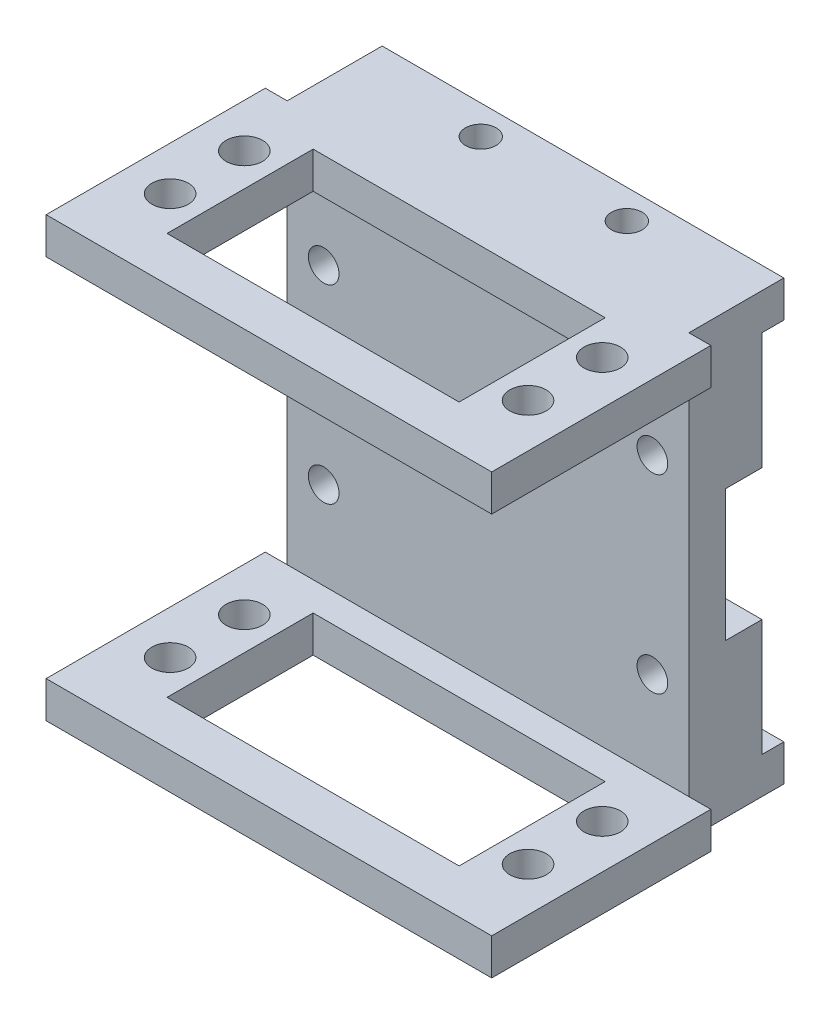
from build123d import *

# Parameters (mm, degrees)
BOSS_EXTRUDE1_DEPTH   = 5
BOSS_EXTRUDE1_2_DEPTH = 5
BOSS_EXTRUDE1_3_DEPTH = 5
BOSS_EXTRUDE1_4_DEPTH = 5
SKETCH2_W             = 55
SKETCH2_H             = 50
BOSS_EXTRUDE2_DEPTH   = 5
SKETCH3_W             = 55
SKETCH3_H             = 13
SKETCH3_R             = 2.1
BOSS_EXTRUDE3_DEPTH   = 5
SKETCH4_W             = 61
SKETCH4_H             = 30
BOSS_EXTRUDE4_DEPTH   = 5
SKETCH5_R             = 2.5
SKETCH5_W             = 39.983210939
SKETCH5_H             = 20
CUT_EXTRUDE3_DEPTH    = 5
SKETCH7_R             = 2.1
CUT_EXTRUDE4_DEPTH    = 14


with BuildPart() as part:
    # Sketch1 → Boss-Extrude1 (new body)
    with BuildSketch(Plane.XY):
        with BuildLine():
            Line((23.840984083, 9.134098408), (28.840984083, 9.134098408))
            Line((28.840984083, 9.134098408), (28.840984083, 25.134098408))
            Line((28.840984083, 25.134098408), (19.840984083, 25.134098408))
            Line((19.840984083, 25.134098408), (19.840984083, 13.134098408))
            ThreePointArc((19.840984083, 13.134098408), (21.012556959, 10.305671284), (23.840984083, 9.134098408))
        make_face()
    extrude(amount=BOSS_EXTRUDE1_DEPTH)



with BuildPart() as body_2:
    # Sketch1 → Boss-Extrude1 2 (new body)
    with BuildSketch(Plane.XY):
        with BuildLine():
            Line((-26.159015917, 9.134098408), (-21.159015917, 9.134098408))
            ThreePointArc((-21.159015917, 9.134098408), (-18.330588792, 10.305671284), (-17.159015917, 13.134098408))
            Line((-17.159015917, 13.134098408), (-17.159015917, 25.134098408))
            Line((-17.159015917, 25.134098408), (-26.159015917, 25.134098408))
            Line((-26.159015917, 25.134098408), (-26.159015917, 9.134098408))
        make_face()
    extrude(amount=BOSS_EXTRUDE1_2_DEPTH)


with BuildPart() as body_3:
    # Sketch1 → Boss-Extrude1 3 (new body)
    with BuildSketch(Plane.XY):
        with BuildLine():
            Line((28.840984083, -8.865901592), (23.840984083, -8.865901592))
            ThreePointArc((23.840984083, -8.865901592), (21.012556959, -10.037474467), (19.840984083, -12.865901592))
            Line((19.840984083, -12.865901592), (19.840984083, -24.865901592))
            Line((19.840984083, -24.865901592), (28.840984083, -24.865901592))
            Line((28.840984083, -24.865901592), (28.840984083, -8.865901592))
        make_face()
    extrude(amount=BOSS_EXTRUDE1_3_DEPTH)


with BuildPart() as body_4:
    # Sketch1 → Boss-Extrude1 4 (new body)
    with BuildSketch(Plane.XY):
        with BuildLine():
            Line((-17.159015917, -24.865901592), (-17.159015917, -12.865901592))
            ThreePointArc((-17.159015917, -12.865901592), (-18.330588792, -10.037474467), (-21.159015917, -8.865901592))
            Line((-21.159015917, -8.865901592), (-26.159015917, -8.865901592))
            Line((-26.159015917, -8.865901592), (-26.159015917, -24.865901592))
            Line((-26.159015917, -24.865901592), (-17.159015917, -24.865901592))
        make_face()
    extrude(amount=BOSS_EXTRUDE1_4_DEPTH)


with BuildPart() as part_1:
    add(part.part)

    add(body_2.part)  # Boss-Extrude2 merges body 2

    add(body_3.part)  # Boss-Extrude2 merges body 3

    add(body_4.part)  # Boss-Extrude2 merges body 4
    # Sketch2 → Boss-Extrude2 (add)
    with BuildSketch(Plane.XY.offset(5)):
        with Locations((1.340984083, 0.134098408)):
            Rectangle(SKETCH2_W, SKETCH2_H)
    extrude(amount=BOSS_EXTRUDE2_DEPTH)

    # Sketch3 → Boss-Extrude3 (add)
    with BuildSketch(Plane(origin=(0, 25.134098408, 0), x_dir=(1, 0, 0), z_dir=(0, 1, 0))):
        with Locations((1.340984083, -3.5)):
            Rectangle(SKETCH3_W, SKETCH3_H)
        with Locations((-8.659015917, -1)):
            Circle(SKETCH3_R, mode=Mode.SUBTRACT)
        with Locations((11.340984083, -1)):
            Circle(SKETCH3_R, mode=Mode.SUBTRACT)
    boss_extrude3 = extrude(amount=BOSS_EXTRUDE3_DEPTH)

    # Mirror1: Boss-Extrude3 across plane
    add(boss_extrude3.mirror(Plane(origin=(0, 0.134098408, 0), x_dir=(0, 0, 1), z_dir=(0, -1, 0))))

    # Sketch4 → Boss-Extrude4 (add)
    with BuildSketch(Plane(origin=(0, 30.134098408, 0), x_dir=(1, 0, 0), z_dir=(0, 1, 0))):
        with Locations((1.340984083, -25)):
            Rectangle(SKETCH4_W, SKETCH4_H)
    boss_extrude4 = extrude(amount=-BOSS_EXTRUDE4_DEPTH)

    # Mirror2: Boss-Extrude4 across plane
    add(boss_extrude4.mirror(Plane(origin=(0, 0.134098408, 0), x_dir=(0, 0, 1), z_dir=(0, -1, 0))))

    # Sketch5 → Cut-Extrude3 (cut)
    with BuildSketch(Plane.XZ.offset(-25.134098408)):
        with Locations((-23.159015917, 29.025922811)):
            Circle(SKETCH5_R)
        with Locations((-23.159015917, 18.865922811)):
            Circle(SKETCH5_R)
        with Locations((25.840984083, 29.025922811)):
            Circle(SKETCH5_R)
        with Locations((25.840984083, 18.865922811)):
            Circle(SKETCH5_R)
        with Locations((1.332589552, 23.945922811)):
            Rectangle(SKETCH5_W, SKETCH5_H)
    cut_extrude3 = extrude(amount=-CUT_EXTRUDE3_DEPTH, mode=Mode.SUBTRACT)

    # Sketch7 → Cut-Extrude4 (cut, through all)
    with BuildSketch(Plane.XY.offset(10)):
        with Locations((23.840984083, -12.865901592)):
            Circle(SKETCH7_R)
        with Locations((-21.159015917, -12.865901592)):
            Circle(SKETCH7_R)
        with Locations((23.840984083, 13.134098408)):
            Circle(SKETCH7_R)
        with Locations((-21.159015917, 13.134098408)):
            Circle(SKETCH7_R)
    extrude(amount=-CUT_EXTRUDE4_DEPTH, mode=Mode.SUBTRACT)

    # Mirror3: Cut-Extrude3 across plane
    add(cut_extrude3.mirror(Plane(origin=(0, 0.134098408, 0), x_dir=(0, 0, 1), z_dir=(0, -1, 0))), mode=Mode.SUBTRACT)


solid = part_1.part
